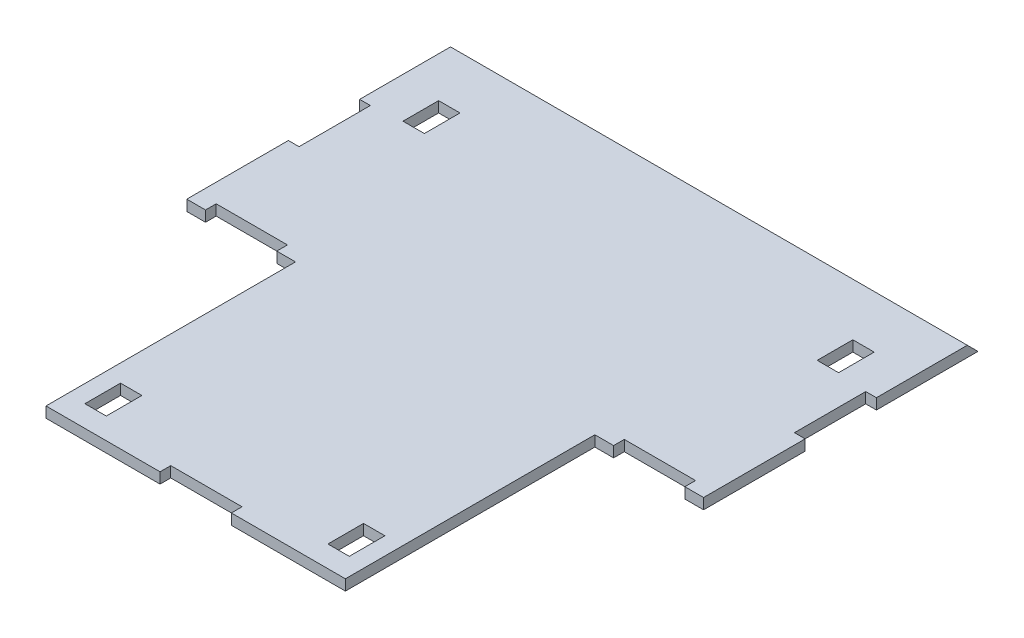
from build123d import *

# Parameters (mm, degrees)
CROQUIS1_W              = 84
CROQUIS1_H              = 70
SALIENTE_EXTRUIR1_DEPTH = 3
CROQUIS2_W              = 6
CROQUIS2_H              = 10
CORTAR_EXTRUIR1_DEPTH   = 3
CROQUIS3_W              = 20
CROQUIS3_H              = 3
CROQUIS3_W_2            = 3
CROQUIS3_H_2            = 20
CORTAR_EXTRUIR2_DEPTH   = 3
CORTAR_EXTRUIR3_DEPTH   = 146


with BuildPart() as part:
    # Croquis1 → Saliente-Extruir1 (new body)
    with BuildSketch(Plane(origin=(0, 0, 0), x_dir=(1, 0, 0), z_dir=(0, 1, 0))):
        Polygon((72.5, 73.5), (-72.5, 73.5), (-72.5, -3.5), (-42, -3.5), (42, -3.5), (72.5, -3.5), align=None)
        with Locations((0, -38.5)):
            Rectangle(CROQUIS1_W, CROQUIS1_H)
    extrude(amount=SALIENTE_EXTRUIR1_DEPTH)

    # Croquis2 → Cortar-Extruir1 (cut)
    with BuildSketch(Plane(origin=(0, 3, 0), x_dir=(1, 0, 0), z_dir=(0, 1, 0))):
        with Locations((-34.09, -62.5)):
            Rectangle(CROQUIS2_W, CROQUIS2_H)
        with Locations((34.09, -62.5)):
            Rectangle(CROQUIS2_W, CROQUIS2_H)
        with Locations((-58.11, 50.77)):
            Rectangle(CROQUIS2_W, CROQUIS2_H)
        with Locations((58.11, 50.77)):
            Rectangle(CROQUIS2_W, CROQUIS2_H)
    extrude(amount=-CORTAR_EXTRUIR1_DEPTH, mode=Mode.SUBTRACT)

    # Croquis3 → Cortar-Extruir2 (cut)
    with BuildSketch(Plane(origin=(0, 3, 0), x_dir=(1, 0, 0), z_dir=(0, 1, 0))):
        with Locations((0, -72)):
            Rectangle(CROQUIS3_W, CROQUIS3_H)
        with Locations((71, 35)):
            Rectangle(CROQUIS3_W_2, CROQUIS3_H_2)
        with Locations((-71, 35)):
            Rectangle(CROQUIS3_W_2, CROQUIS3_H_2)
        with Locations((57.25, -2)):
            Rectangle(CROQUIS3_W, CROQUIS3_H)
        with Locations((-57.25, -2)):
            Rectangle(CROQUIS3_W, CROQUIS3_H)
    extrude(amount=-CORTAR_EXTRUIR2_DEPTH, mode=Mode.SUBTRACT)

    # Croquis5 → Cortar-Extruir3 (cut, through all)
    with BuildSketch(Plane(origin=(72.5, 0, 0), x_dir=(0, 0, -1), z_dir=(1, 0, 0))):
        Polygon((73.5, 0), (70.5, 3), (73.5, 3), align=None)
    extrude(amount=-CORTAR_EXTRUIR3_DEPTH, mode=Mode.SUBTRACT)


solid = part.part
